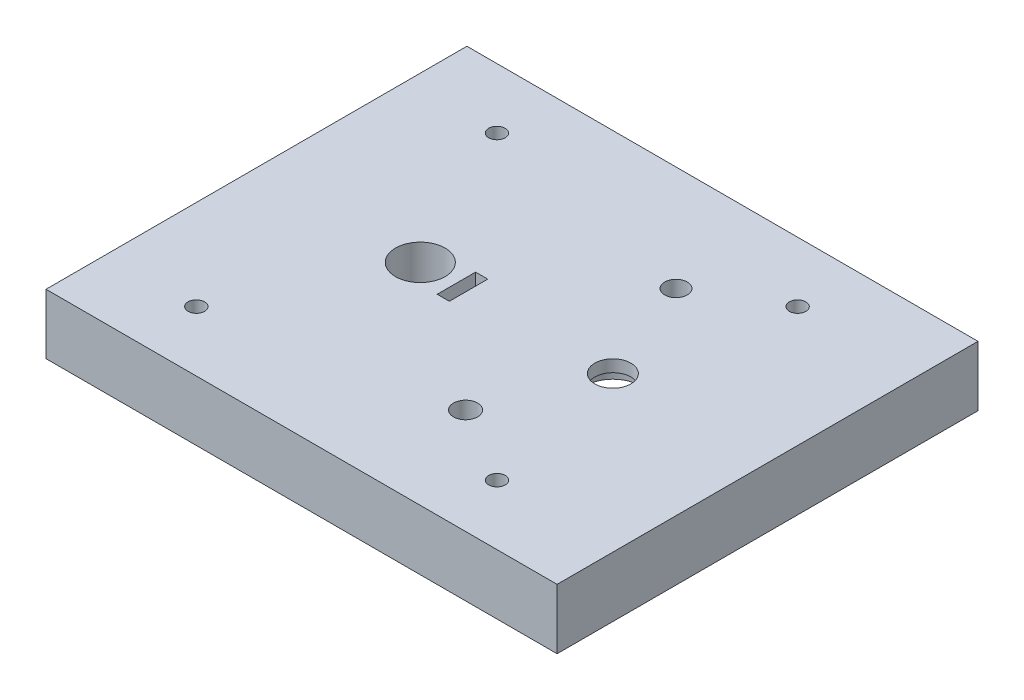
from build123d import *

# Parameters (mm, degrees)
SKETCH1_W           = 85
SKETCH1_H           = 70
SKETCH1_R           = 1.375
SKETCH1_R_2         = 4.125
SKETCH1_W_2         = 2.024682369
SKETCH1_H_2         = 6.385975888
SKETCH1_R_3         = 1.875
SKETCH1_R_4         = 2
SKETCH1_R_5         = 3
BOSS_EXTRUDE4_DEPTH = 10
SKETCH1_7_R         = 2
SKETCH1_7_R_2       = 4.5
SKETCH1_7_R_3       = 1.875
CUT_EXTRUDE2_DEPTH  = 6
SKETCH1_11_R        = 4.5
SKETCH1_11_R_2      = 3
CUT_EXTRUDE10_DEPTH = 8


with BuildPart() as part:
    # Sketch1 → Boss-Extrude4 (new body)
    with BuildSketch(Plane(origin=(0, 0, 0), x_dir=(1, 0, 0), z_dir=(0, 1, 0))):
        with Locations((-9.775924906, 0)):
            Rectangle(SKETCH1_W, SKETCH1_H)
        with Locations((-37.275924906, -25)):
            Circle(SKETCH1_R, mode=Mode.SUBTRACT)
        with Locations((12.724075094, -25)):
            Circle(SKETCH1_R, mode=Mode.SUBTRACT)
        with Locations((-25.024682369, 0)):
            Circle(SKETCH1_R_2, mode=Mode.SUBTRACT)
        with Locations((-18.012341185, 0)):
            Rectangle(SKETCH1_W_2, SKETCH1_H_2, mode=Mode.SUBTRACT)
        with Locations((-37.275924906, 25)):
            Circle(SKETCH1_R, mode=Mode.SUBTRACT)
        with Locations((12.724075094, 25)):
            Circle(SKETCH1_R, mode=Mode.SUBTRACT)
        with Locations((0, 17.5)):
            Circle(SKETCH1_R_3, mode=Mode.SUBTRACT)
        with Locations((0, -17.5)):
            Circle(SKETCH1_R_4, mode=Mode.SUBTRACT)
        with Locations((7, 0)):
            Circle(SKETCH1_R_5, mode=Mode.SUBTRACT)
    extrude(amount=BOSS_EXTRUDE4_DEPTH)

    # Sketch1_7 → Cut-Extrude2 (cut)
    with BuildSketch(Plane(origin=(0, 0, 0), x_dir=(1, 0, 0), z_dir=(0, 1, 0))):
        with BuildLine():
            Line((3.625, 13.729507457), (3.625, 17.5))
            ThreePointArc((3.625, 17.5), (0, 21.125), (-3.625, 17.5))
            Line((-3.625, 17.5), (-3.625, 13.729507457))
            ThreePointArc((-3.625, 13.729507457), (-8.669470541, 11.246345208), (-12.354756169, 7))
            Line((-12.354756169, 7), (-17, 7))
            Line((-17, 7), (-17, 3.192987944))
            Line((-17, 3.192987944), (-19.024682369, 3.192987944))
            Line((-19.024682369, 3.192987944), (-19.024682369, -3.192987944))
            Line((-19.024682369, -3.192987944), (-17, -3.192987944))
            Line((-17, -3.192987944), (-17, -7))
            Line((-17, -7), (-12.354756169, -7))
            ThreePointArc((-12.354756169, -7), (-8.669470541, -11.246345208), (-3.625, -13.729507457))
            Line((-3.625, -13.729507457), (-3.625, -17.5))
            ThreePointArc((-3.625, -17.5), (0, -21.125), (3.625, -17.5))
            Line((3.625, -17.5), (3.625, -13.729507457))
            ThreePointArc((3.625, -13.729507457), (14.2, 0), (3.625, 13.729507457))
        make_face()
        with Locations((0, -17.5)):
            Circle(SKETCH1_7_R, mode=Mode.SUBTRACT)
        with Locations((7, 0)):
            Circle(SKETCH1_7_R_2, mode=Mode.SUBTRACT)
        with Locations((0, 17.5)):
            Circle(SKETCH1_7_R_3, mode=Mode.SUBTRACT)
    extrude(amount=CUT_EXTRUDE2_DEPTH, mode=Mode.SUBTRACT)

    # Sketch1_11 → Cut-Extrude10 (cut)
    with BuildSketch(Plane(origin=(0, 0, 0), x_dir=(1, 0, 0), z_dir=(0, 1, 0))):
        with Locations((7, 0)):
            Circle(SKETCH1_11_R)
        with Locations((7, 0)):
            Circle(SKETCH1_11_R_2, mode=Mode.SUBTRACT)
    extrude(amount=CUT_EXTRUDE10_DEPTH, mode=Mode.SUBTRACT)


solid = part.part
